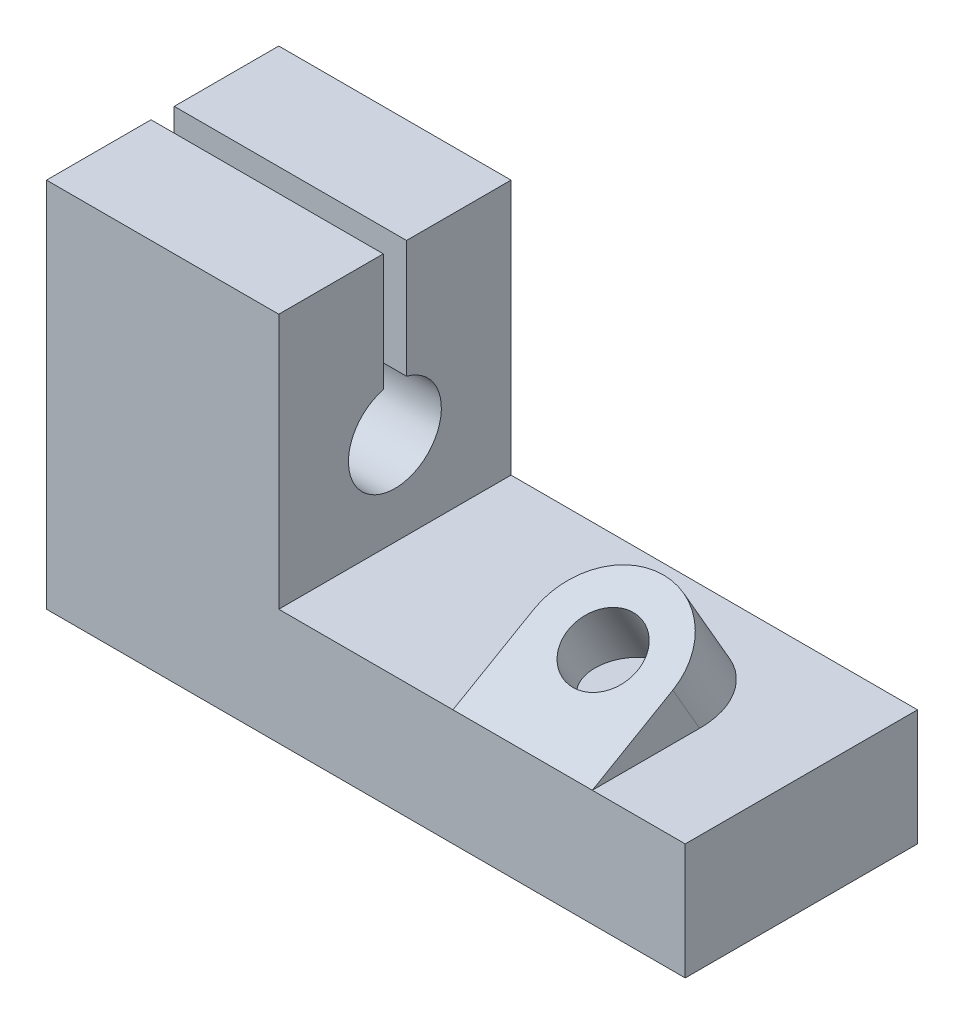
from build123d import *

# Parameters (mm, degrees)
BOSS_EXTRUDE1_DEPTH = 10
CUT_EXTRUDE1_DEPTH  = 21
BOSS_EXTRUDE2_REACH = 20.66
SKETCH3_R           = 3


with BuildPart() as part:
    # Sketch1 → Boss-Extrude1 (new body, symmetric)
    with BuildSketch(Plane.XY):
        Polygon((0, 0), (55, 0), (55, 10), (20, 10), (20, 32), (0, 32), align=None)
    extrude(amount=BOSS_EXTRUDE1_DEPTH, both=True)

    # Sketch2 → Cut-Extrude1 (cut, through all)
    with BuildSketch(Plane(origin=(20, 0, 0), x_dir=(0, 0, -1), z_dir=(1, 0, 0))):
        with BuildLine():
            Line((-1, 32), (1, 32))
            Line((1, 32), (1, 21.872983346))
            ThreePointArc((1, 21.872983346), (0, 14), (-1, 21.872983346))
            Line((-1, 21.872983346), (-1, 32))
        make_face()
    extrude(amount=-CUT_EXTRUDE1_DEPTH, mode=Mode.SUBTRACT)

    # Sketch3 → Boss-Extrude2 (add, up to next)
    with BuildSketch(Plane(origin=(0, 11.830127019, 6.830127019), x_dir=(-1, 0, 0), z_dir=(0, 0.866025404, 0.5)), mode=Mode.PRIVATE) as boss_extrude2_sk1:
        with BuildLine():
            Line((-47, 3.660254038), (-35, 3.660254038))
            Line((-35, 3.660254038), (-35, -4.339745962))
            ThreePointArc((-35, -4.339745962), (-41, -10.339745962), (-47, -4.339745962))
            Line((-47, -4.339745962), (-47, 3.660254038))
        make_face()
        with Locations(Location((-41, -4.339745962, 0), (0, 0, 90))):  # turned: the seam where the file's is
            Circle(SKETCH3_R, mode=Mode.SUBTRACT)
    boss_extrude2_tool1 = extrude(boss_extrude2_sk1.sketch, amount=-BOSS_EXTRUDE2_REACH, mode=Mode.PRIVATE) - part.part
    add(boss_extrude2_tool1.solids().sort_by_distance((41, 10.092195, 9.840313))[0])


solid = part.part
